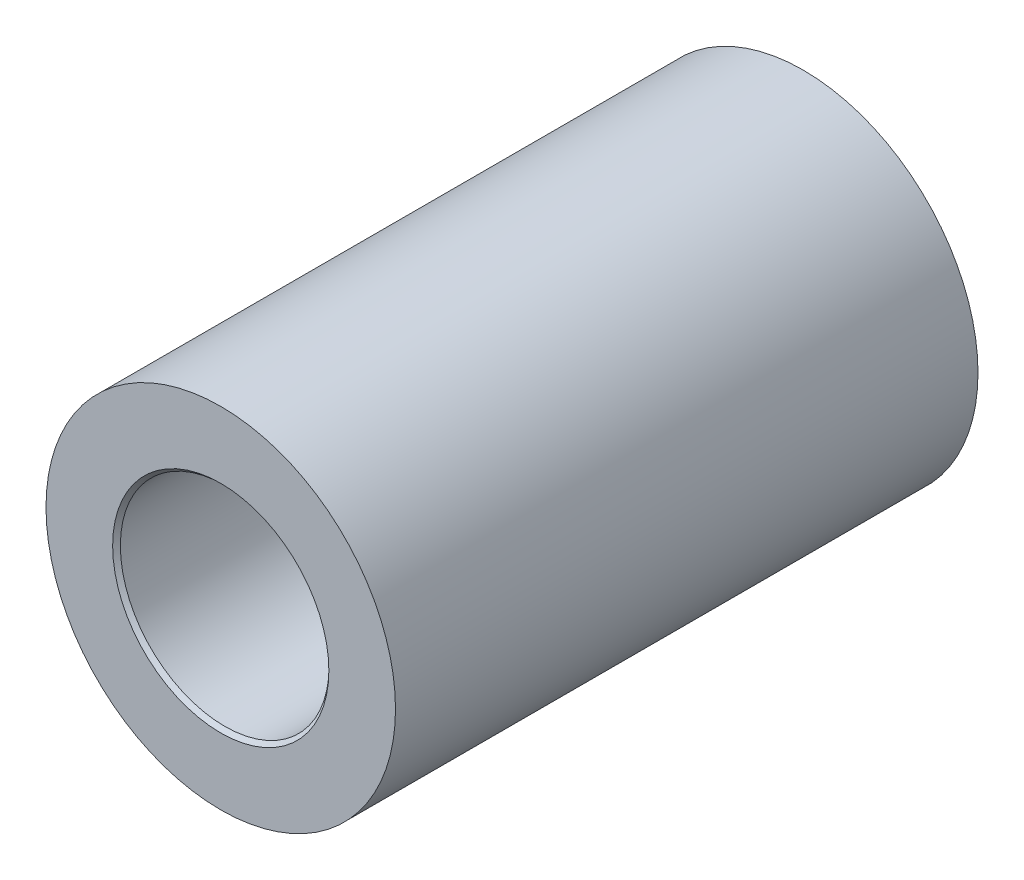
from build123d import *

# Parameters (mm, degrees)
EXTRUDE1_DEPTH      = 3.96875
EXTRUDE1_DEPTH_BACK = 3.96875
SKETCH1_R           = 3.175
SKETCH1_R_2         = 1.4224
SKETCH13_OUTSIDE_W  = 10.748
SKETCH13_OUTSIDE_H  = 10.748
SKETCH13_OUTSIDE_R  = 2.38125
CUT_EXTRUDE1_DEPTH  = 10.119493201


with BuildPart() as part:
    # Sketch1 → Extrude1 (new, two sides: drawn at the far end of the back side and taken through both)
    with BuildSketch(Plane.XY.offset(-EXTRUDE1_DEPTH_BACK)):
        Circle(SKETCH1_R)
        Circle(SKETCH1_R_2, mode=Mode.SUBTRACT)
    extrude(amount=EXTRUDE1_DEPTH + EXTRUDE1_DEPTH_BACK)

    # Extrude3 cone 1 section (through the dimple's axis) → Extrude3 (revolve, cut)
    with BuildSketch(Plane(origin=(0, 0, -3.96875), x_dir=(0, 1, 0), z_dir=(1, 0, 0))):
        Polygon((0, 0), (1.4732, 0), (0, 1.579813584), align=None)
    extrude3 = revolve(axis=Axis((0, 0, -3.96875), (0, 0, 1)), mode=Mode.SUBTRACT)

    # Mirror1: Extrude3 across plane
    add(extrude3.mirror(Plane.XY), mode=Mode.SUBTRACT)

    # Sketch13 outside → Cut-Extrude1 (cut, through all)
    with BuildSketch(Plane.XY.offset(3.96875)):
        Rectangle(SKETCH13_OUTSIDE_W, SKETCH13_OUTSIDE_H)
        Circle(SKETCH13_OUTSIDE_R, mode=Mode.SUBTRACT)
    extrude(amount=-CUT_EXTRUDE1_DEPTH, mode=Mode.SUBTRACT)


solid = part.part
